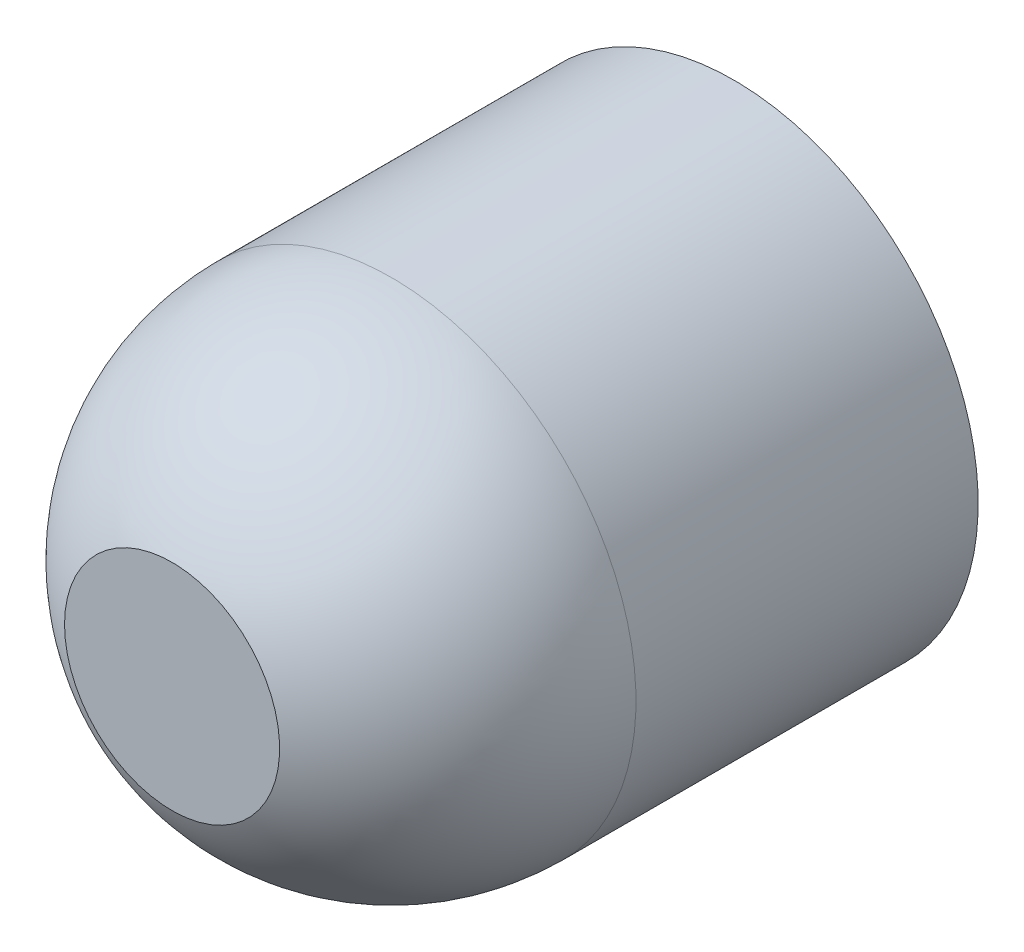
from build123d import *

# Parameters (mm, degrees)
VYSUNOUT1_DEPTH = 11.8


with BuildPart() as part:
    # Skica1 → Rotovat1 (revolve)
    with BuildSketch(Plane(origin=(0, 0, 0), x_dir=(1, 0, 0), z_dir=(0, 1, 0)), mode=Mode.PRIVATE) as rotovat1_sk:
        with BuildLine():
            Line((0, 0), (12.5, 0))
            Line((12.5, 0), (12.5, -17.5))
            ThreePointArc((12.5, -17.5), (8.838834765, -26.338834765), (0, -30))
            Line((0, -30), (0, 0))
        make_face()
    revolve(rotovat1_sk.sketch.rotate(Axis((0, 0, 0), (0, 0, 1)), 180), axis=Axis((0, 0, 0), (0, 0, 1)))  # turned: the seam where the file's is

    # Skica2 → Vysunout1 (cut, symmetric)
    with BuildSketch(Plane(origin=(0, 0, 0), x_dir=(1, 0, 0), z_dir=(0, 1, 0))):
        with BuildLine():
            Line((-5.5, -28.72497216), (5.5, -28.72497216))
            ThreePointArc((5.5, -28.72497216), (0, -30), (-5.5, -28.72497216))
        make_face()
    extrude(amount=VYSUNOUT1_DEPTH, both=True, mode=Mode.SUBTRACT)


solid = part.part
